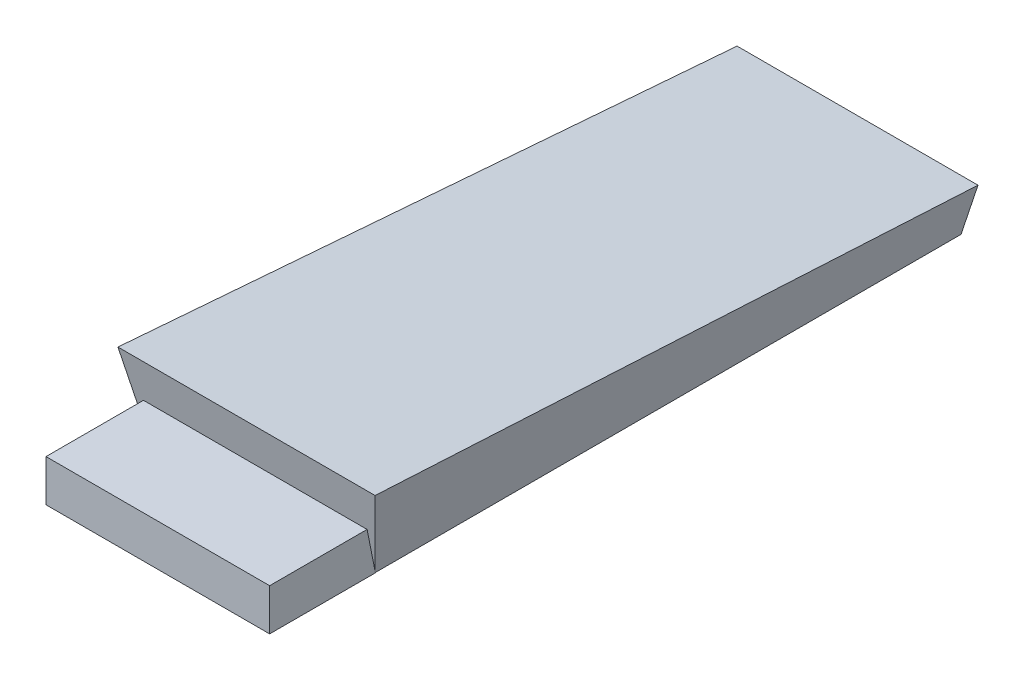
from build123d import *

# Parameters (mm, degrees)
SKETCH1_W             = 203.2
SKETCH1_H             = 368.3
BOSS_EXTRUDE4_DEPTH   = 254
BOSS_EXTRUDE4_TAPER   = 11.25
CUT_EXTRUDE1_DEPTH    = 254
BOSS_EXTRUDE5_START   = -151.75
BOSS_EXTRUDE5_DEPTH   = 102
BODY_MOVE_COPY1_ANGLE = 180


with BuildPart() as part:
    # Sketch1 → Boss-Extrude4 (new body)
    with BuildSketch(Plane(origin=(0, 0, 0), x_dir=(1, 0, 0), z_dir=(0, 1, 0))):
        with Locations((-183.252356021, -50.101832461)):
            Rectangle(SKETCH1_W, SKETCH1_H)
    extrude(amount=BOSS_EXTRUDE4_DEPTH, taper=BOSS_EXTRUDE4_TAPER)

    # Sketch2 → Cut-Extrude1 (cut)
    with BuildSketch(Plane(origin=(-82.7176, 0, 0), x_dir=(0, 0, -1), z_dir=(1, 0, 0))):
        Polygon((-234.106807468, 0), (147.485457697, 0), (93.149429588, 234.95), (-191.90501696, 215.9), align=None)
    extrude(amount=-CUT_EXTRUDE1_DEPTH, mode=Mode.SUBTRACT)


with BuildPart() as cut_extrude1_kept_piece:
    # of the separate pieces the step leaves, the one the design keeps (cut_extrude1_pieces_kept)
    add(part.part.solids().sort_by_distance((-238.194452935, 234.565118806, -87.390264453))[0])

    # Sketch3 → Boss-Extrude5 (add)
    with BuildSketch(Plane(origin=(-82.7176, 0, 0), x_dir=(0, 0, -1), z_dir=(1, 0, 0)).offset(BOSS_EXTRUDE5_START)):
        Polygon((-183.728091146, 254), (-231.967371745, 254), (-231.967371745, 234.95), (-187.517371745, 234.95), align=None)
    extrude(amount=BOSS_EXTRUDE5_DEPTH)


with BuildPart() as cut_extrude1_kept_piece_1:
    # Body-Move/Copy1: moved
    add(cut_extrude1_kept_piece.part.rotate(Axis((-183.252356021, 234.970263522, 0), (0, 0, 1)), BODY_MOVE_COPY1_ANGLE))


solid = cut_extrude1_kept_piece_1.part
